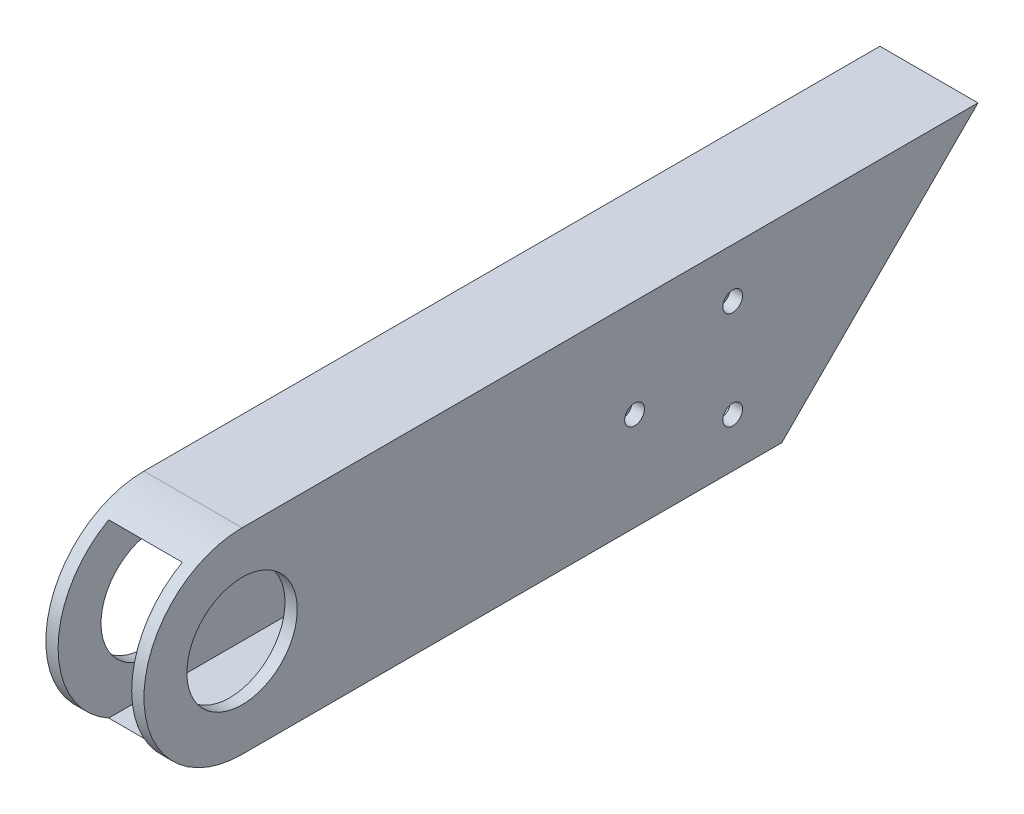
from build123d import *

# Parameters (mm, degrees)
SKETCH1_W               = 25.4
SKETCH1_H               = 50.8
SKETCH1_W_2             = 19.05
SKETCH1_H_2             = 44.45
BOSS_EXTRUDE1_DEPTH     = 215.9
CUT_EXTRUDE1_DEPTH      = 25.4
SKETCH3_R               = 2.5527
CUT_EXTRUDE2_DEPTH      = 25.4
CUT_EXTRUDE_THIN1_DEPTH = 26.4
SKETCH7_R               = 14.2875
CUT_EXTRUDE3_DEPTH      = 25.4


with BuildPart() as part:
    # Sketch1 → Boss-Extrude1 (new body)
    with BuildSketch(Plane.XY):
        with Locations((-12.7, 25.4)):
            Rectangle(SKETCH1_W, SKETCH1_H)
        with Locations((-12.7, 25.4)):
            Rectangle(SKETCH1_W_2, SKETCH1_H_2, mode=Mode.SUBTRACT)
    extrude(amount=BOSS_EXTRUDE1_DEPTH)

    # Sketch2 → Cut-Extrude1 (cut)
    with BuildSketch(Plane(origin=(0, 0, 0), x_dir=(0, 0, -1), z_dir=(1, 0, 0))):
        Polygon((0, 50.8), (-50.8, 0), (0, 0), align=None)
    extrude(amount=-CUT_EXTRUDE1_DEPTH, mode=Mode.SUBTRACT)

    # Sketch3 → Cut-Extrude2 (cut)
    with BuildSketch(Plane(origin=(0, 0, 0), x_dir=(0, 0, -1), z_dir=(1, 0, 0))):
        with Locations((-63.5, 38.1)):
            Circle(SKETCH3_R)
        with Locations((-63.5, 12.7)):
            Circle(SKETCH3_R)
        with Locations((-88.9, 25.4)):
            Circle(SKETCH3_R)
    extrude(amount=-CUT_EXTRUDE2_DEPTH, mode=Mode.SUBTRACT)

    # Sketch6 → Cut-Extrude-Thin1 (cut, through all)
    with BuildSketch(Plane(origin=(0, 0, 0), x_dir=(0, 0, -1), z_dir=(1, 0, 0))):
        with BuildLine():
            ThreePointArc((-190.5, 0), (-215.9, 25.4), (-190.5, 50.8))
            Line((-190.5, 50.8), (-190.5, 63.5))
            ThreePointArc((-190.5, 63.5), (-228.6, 25.4), (-190.5, -12.7))
            Line((-190.5, -12.7), (-190.5, 0))
        make_face()
    extrude(amount=-CUT_EXTRUDE_THIN1_DEPTH, mode=Mode.SUBTRACT)

    # Sketch7 → Cut-Extrude3 (cut)
    with BuildSketch(Plane(origin=(0, 0, 0), x_dir=(0, 0, -1), z_dir=(1, 0, 0))):
        with Locations((-190.5, 25.4)):
            Circle(SKETCH7_R)
    extrude(amount=-CUT_EXTRUDE3_DEPTH, mode=Mode.SUBTRACT)


solid = part.part
